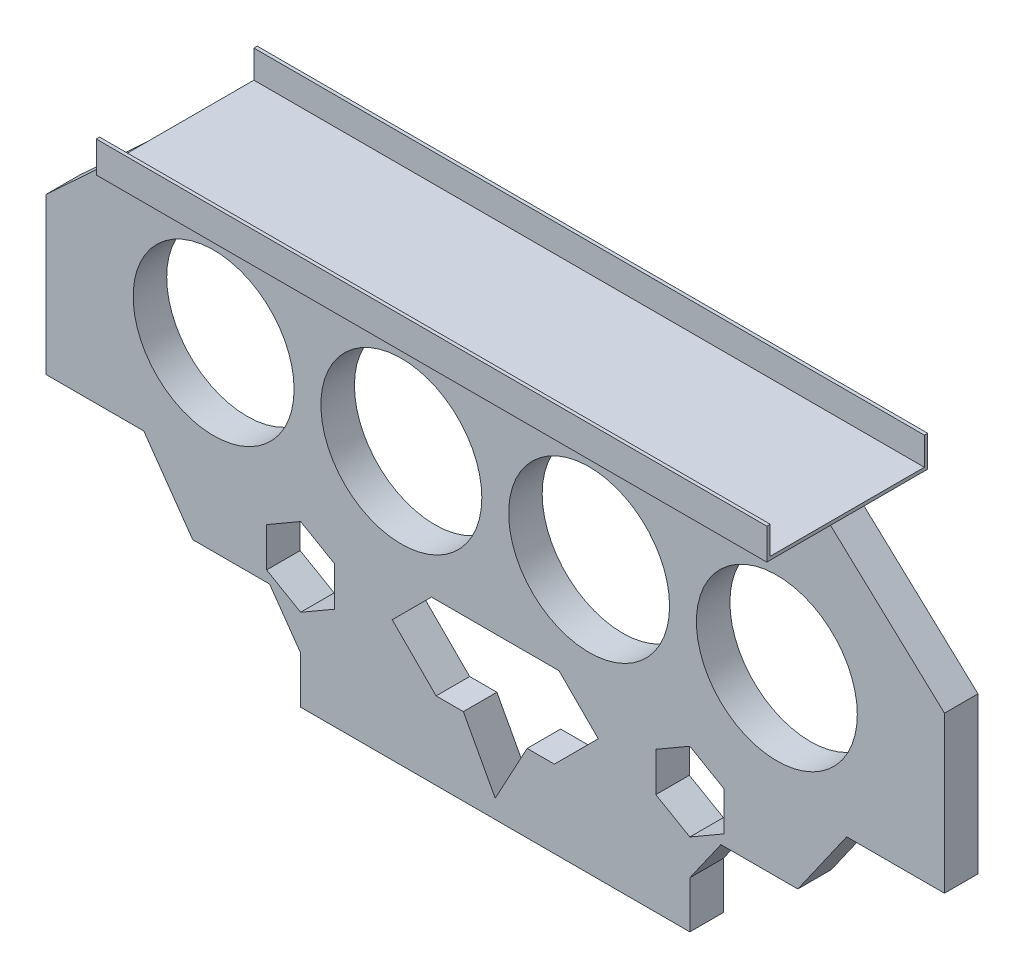
from build123d import *

# Parameters (mm, degrees)
SKETCH1_W           = 134
SKETCH1_H           = 63
BOSS_EXTRUDE1_DEPTH = 5
SKETCH3_R           = 12
CUT_EXTRUDE1_DEPTH  = 10
CUT_EXTRUDE2_DEPTH  = 10
BOSS_EXTRUDE2_DEPTH = 100


with BuildPart() as part:
    # Sketch1 → Boss-Extrude1 (new body)
    with BuildSketch(Plane.XY):
        Rectangle(SKETCH1_W, SKETCH1_H)
    extrude(amount=-BOSS_EXTRUDE1_DEPTH)

    # Sketch3 → Cut-Extrude1 (cut)
    with BuildSketch(Plane.XY):
        with Locations((-42, 9.071273883)):
            Circle(SKETCH3_R)
        with Locations((-14, 9.071273883)):
            Circle(SKETCH3_R)
        with Locations((14, 9.071273883)):
            Circle(SKETCH3_R)
        with Locations((42, 9.071273883)):
            Circle(SKETCH3_R)
    extrude(amount=-CUT_EXTRUDE1_DEPTH, mode=Mode.SUBTRACT)

    # Sketch4 → Cut-Extrude2 (cut)
    with BuildSketch(Plane.XY):
        Polygon((-67, -7.520628775), (-52.411804658, -7.520628775), (-45.12377265, -17.909951), (-33.648998849, -17.909951), (-29.023524966, -24.503711642), (-29.023524966, -31.5), (-67, -31.5), align=None)
        Polygon((67, -7.520628775), (67, -31.5), (29.023524966, -31.5), (29.023524966, -24.503711642), (33.648998849, -17.909951), (45.12377265, -17.909951), (52.411804658, -7.520628775), align=None)
        Polygon((-50, 31.5), (-67, 15.739047849), (-67, 31.5), align=None)
        Polygon((67, 15.739047849), (67, 31.5), (50, 31.5), align=None)
        Polygon((9.511401459, -7.520628775), (-9.511401459, -7.520628775), (-15.370004361, -13.379231677), (-8.815992906, -19.933243133), (-4.75570073, -19.933243133), (-2.290700849, -24.503711642), (0, -28.751004381), (2.290700849, -24.503711642), (4.75570073, -19.933243133), (8.815992906, -19.933243133), (15.370004361, -13.379231677), align=None)
        Polygon((-34.097223909, -10.449930226), (-29.023524966, -7.520628775), (-23.949826022, -10.449930226), (-23.949826022, -16.308533128), (-29.023524966, -19.237834579), (-34.097223909, -16.308533128), align=None)
        Polygon((29.023524966, -7.520628775), (23.949826022, -10.449930226), (23.949826022, -16.308533128), (29.023524966, -19.237834579), (34.097223909, -16.308533128), (34.097223909, -10.449930226), align=None)
    extrude(amount=-CUT_EXTRUDE2_DEPTH, mode=Mode.SUBTRACT)

    # Sketch5 → Boss-Extrude2 (add)
    with BuildSketch(Plane(origin=(50, 0, 0), x_dir=(0, 0, -1), z_dir=(1, 0, 0))):
        Polygon((-9.5, 31.5), (14.5, 31.5), (14.5, 36.149124197), (14, 36.149124197), (14, 32), (-9, 32), (-9, 36.149124197), (-9.5, 36.149124197), align=None)
    extrude(amount=-BOSS_EXTRUDE2_DEPTH)


solid = part.part
